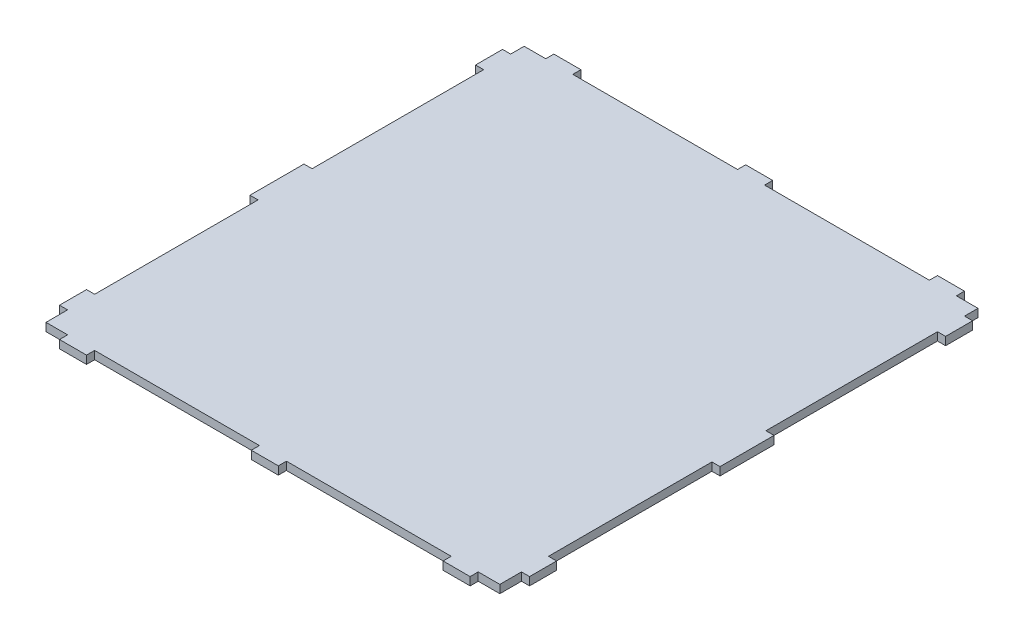
from build123d import *

# Parameters (mm, degrees)
BOSS_EXTRUDE1_DEPTH = 3


with BuildPart() as part:
    # Sketch1 → Boss-Extrude1 (new body)
    with BuildSketch(Plane(origin=(0, 0, 0), x_dir=(1, 0, 0), z_dir=(0, 1, 0))):
        Polygon((-114.600863387, -60.5), (-114.600863387, 0), (-117.600863387, 0), (-117.600863387, 20), (-114.600863387, 20), (-114.600863387, 83.5), (-117.600863387, 83.5), (-117.600863387, 93.5), (-114.600863387, 93.5), (-114.600863387, 98.5), (-106.600863387, 98.5), (-106.600863387, 101.5), (-96.600863387, 101.5), (-96.600863387, 98.5), (-35.600863387, 98.5), (-35.600863387, 101.5), (-25.600863387, 101.5), (-25.600863387, 98.5), (35.399136613, 98.5), (35.399136613, 101.5), (45.399136613, 101.5), (45.399136613, 98.5), (53.399136613, 98.5), (53.399136613, 93.5), (56.399136613, 93.5), (56.399136613, 83.5), (53.399136613, 83.5), (53.399136613, 20), (56.399136613, 20), (56.399136613, 0), (53.399136613, 0), (53.399136613, -60.5), (56.399136613, -60.5), (56.399136613, -70.5), (53.399136613, -70.5), (53.399136613, -78.5), (45.399136613, -78.5), (45.399136613, -81.5), (35.399136613, -81.5), (35.399136613, -78.5), (-25.600863387, -78.5), (-25.600863387, -81.5), (-35.600863387, -81.5), (-35.600863387, -78.5), (-96.600863387, -78.5), (-96.600863387, -81.5), (-106.600863387, -81.5), (-106.600863387, -78.5), (-114.600863387, -78.5), (-114.600863387, -70.5), (-117.600863387, -70.5), (-117.600863387, -60.5), align=None)
    extrude(amount=BOSS_EXTRUDE1_DEPTH)


solid = part.part
